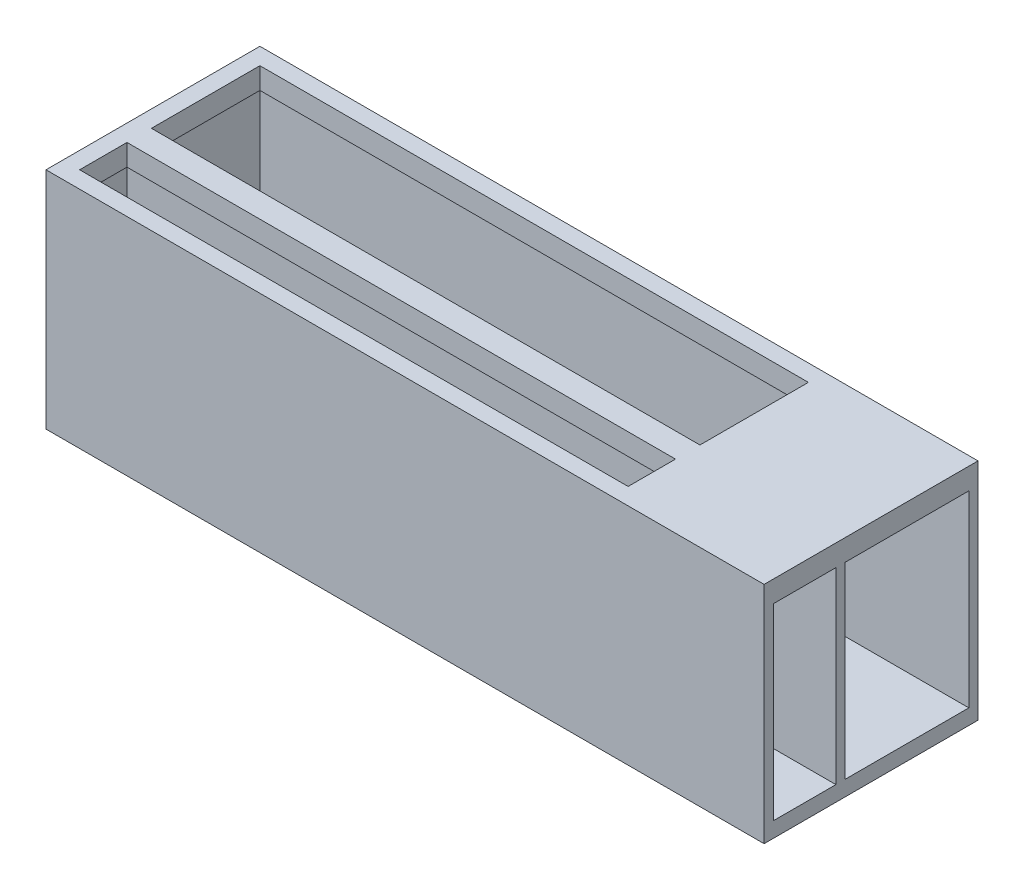
from build123d import *

# Parameters (mm, degrees)
SKETCH1_W           = 119.38
SKETCH1_H           = 35.56
BOSS_EXTRUDE1_DEPTH = 37.338
SKETCH2_W           = 10.414
SKETCH2_H           = 31.242
SKETCH2_W_2         = 20.574
CUT_EXTRUDE1_DEPTH  = 117.856
CUT_EXTRUDE2_REACH  = 39.338
SKETCH3_W           = 91.186
SKETCH3_H           = 18.034
SKETCH3_H_2         = 7.874


with BuildPart() as part:
    # Sketch1 → Boss-Extrude1 (new body)
    with BuildSketch(Plane(origin=(0, 0, 0), x_dir=(1, 0, 0), z_dir=(0, 1, 0))):
        Rectangle(SKETCH1_W, SKETCH1_H)
    extrude(amount=BOSS_EXTRUDE1_DEPTH)

    # Sketch2 → Cut-Extrude1 (cut)
    with BuildSketch(Plane(origin=(59.69, 0, 0), x_dir=(0, 0, -1), z_dir=(1, 0, 0))):
        with Locations((-11.049, 18.161)):
            Rectangle(SKETCH2_W, SKETCH2_H)
        with Locations((5.969, 18.161)):
            Rectangle(SKETCH2_W_2, SKETCH2_H)
    extrude(amount=-CUT_EXTRUDE1_DEPTH, mode=Mode.SUBTRACT)

    # Sketch3 → Cut-Extrude2 (cut, up to next)
    with BuildSketch(Plane(origin=(0, 37.338, 0), x_dir=(1, 0, 0), z_dir=(0, 1, 0)), mode=Mode.PRIVATE) as cut_extrude2_sk1:
        with Locations((-11.303, 5.969)):
            Rectangle(SKETCH3_W, SKETCH3_H)
    cut_extrude2_tool1 = extrude(cut_extrude2_sk1.sketch, amount=-CUT_EXTRUDE2_REACH, mode=Mode.PRIVATE) & part.part
    add(cut_extrude2_tool1.solids().sort_by_distance((-11.303, 37.338, -5.969))[0], mode=Mode.SUBTRACT)
    # Sketch3 → Cut-Extrude2 (cut, up to next)
    with BuildSketch(Plane(origin=(0, 37.338, 0), x_dir=(1, 0, 0), z_dir=(0, 1, 0)), mode=Mode.PRIVATE) as cut_extrude2_sk2:
        with Locations((-11.303, -11.049)):
            Rectangle(SKETCH3_W, SKETCH3_H_2)
    cut_extrude2_tool2 = extrude(cut_extrude2_sk2.sketch, amount=-CUT_EXTRUDE2_REACH, mode=Mode.PRIVATE) & part.part
    add(cut_extrude2_tool2.solids().sort_by_distance((-11.303, 37.338, 11.049))[0], mode=Mode.SUBTRACT)


solid = part.part
